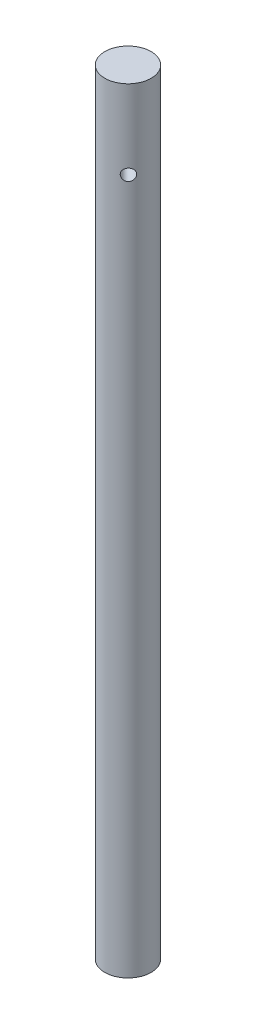
from build123d import *

# Parameters (mm, degrees)
SKETCH1_R                 = 2.99
BOSS_EXTRUDE1_DEPTH       = 100
F_1_5MM_DOWEL_HOLE5_D     = 1.5
F_1_5MM_DOWEL_HOLE5_DEPTH = 20
F_1_5MM_DOWEL_HOLE5_TIP   = 0.450645464


with BuildPart() as part:
    # Sketch1 → Boss-Extrude1 (new body)
    with BuildSketch(Plane(origin=(0, 0, 0), x_dir=(1, 0, 0), z_dir=(0, 1, 0))):
        Circle(SKETCH1_R)
    extrude(amount=BOSS_EXTRUDE1_DEPTH)

    # Ø1.5mm Dowel Hole5
    with Locations(Plane(origin=(2.144246544, 89.818322141, 2.083820232), x_dir=(-0.696929844, 0, 0.717139312), z_dir=(0.717139312, 0, 0.696929844))):
        with Locations((0, 0)):
            Hole(F_1_5MM_DOWEL_HOLE5_D / 2, depth=F_1_5MM_DOWEL_HOLE5_DEPTH)
            with Locations((0, 0, -(F_1_5MM_DOWEL_HOLE5_DEPTH + F_1_5MM_DOWEL_HOLE5_TIP / 2))):  # 118° drill point
                Cone(0, F_1_5MM_DOWEL_HOLE5_D / 2, F_1_5MM_DOWEL_HOLE5_TIP, mode=Mode.SUBTRACT)


solid = part.part
